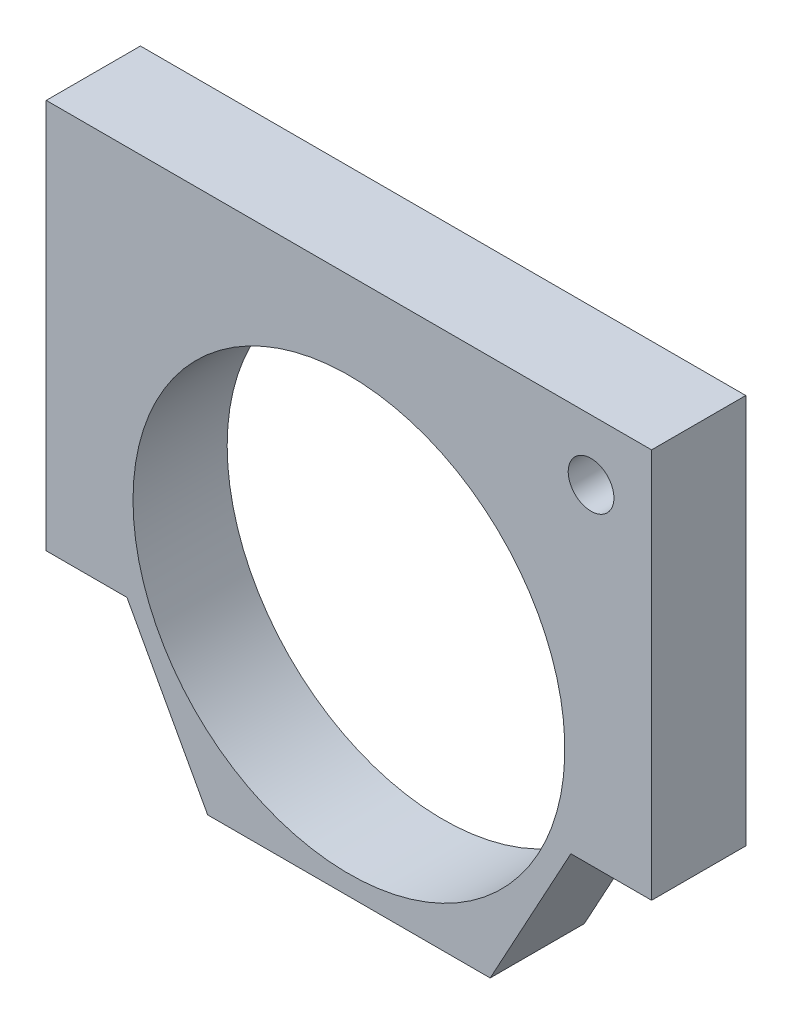
from build123d import *

# Parameters (mm, degrees)
SKETCH1_W                       = 45
SKETCH1_H                       = 40
SKETCH1_R                       = 16
BOSS_EXTRUDE1_DEPTH             = 3.5
M3X0_5_TAPPED_HOLE2_D           = 2.5
M3X0_5_TAPPED_HOLE2_DEPTH       = 25
M3X0_5_TAPPED_HOLE2_TIP         = 0.751075774
CUT_EXTRUDE1_DEPTH              = 5
CBORE_FOR_M3_SBHCS1_D           = 3.4
CBORE_FOR_M3_SBHCS1_DEPTH       = 7
CBORE_FOR_M3_SBHCS1_CBORE_D     = 6.7
CBORE_FOR_M3_SBHCS1_CBORE_DEPTH = 2.65
CBORE_FOR_M3_SBHCS1_TIP         = 1.021463052
F_3D_PRINTING_TOLERANCE_BY      = 0.05


with BuildPart() as part:
    # Sketch1 → Boss-Extrude1 (new, symmetric)
    with BuildSketch(Plane.XY):
        Rectangle(SKETCH1_W, SKETCH1_H)
        with Locations((0, -2.5)):
            Circle(SKETCH1_R, mode=Mode.SUBTRACT)
    extrude(amount=BOSS_EXTRUDE1_DEPTH, both=True)

    # M3x0.5 Tapped Hole2
    with Locations(Plane(origin=(0, -25, 71.05), x_dir=(0, 0, 1), z_dir=(0, -1, 0))):
        with Locations((-41.05, -18.5), (-71.05, 18.5), (-71.05, -18.5), (-41.05, 18.5)):
            Hole(M3X0_5_TAPPED_HOLE2_D / 2, depth=M3X0_5_TAPPED_HOLE2_DEPTH)
            with Locations((0, 0, -(M3X0_5_TAPPED_HOLE2_DEPTH + M3X0_5_TAPPED_HOLE2_TIP / 2))):  # 118° drill point
                Cone(0, M3X0_5_TAPPED_HOLE2_D / 2, M3X0_5_TAPPED_HOLE2_TIP, mode=Mode.SUBTRACT)

    # Sketch7 → Cut-Extrude1 (cut, symmetric)
    with BuildSketch(Plane.XY):
        Polygon((10.5, -20), (16.5, -9), (22.5, -9), (22.5, -20), align=None)
        Polygon((-10.5, -20), (-16.5, -9), (-22.5, -9), (-22.5, -20), align=None)
    extrude(amount=CUT_EXTRUDE1_DEPTH, both=True, mode=Mode.SUBTRACT)

    # CBORE for M3 SBHCS1
    with Locations(Plane(origin=(0, -2.5, -3.5), x_dir=(-1, 0, 0), z_dir=(0, 0, -1))):
        with Locations((-18, 18)):
            CounterBoreHole(CBORE_FOR_M3_SBHCS1_D / 2, CBORE_FOR_M3_SBHCS1_CBORE_D / 2, CBORE_FOR_M3_SBHCS1_CBORE_DEPTH, depth=CBORE_FOR_M3_SBHCS1_DEPTH)
            with Locations((0, 0, -(CBORE_FOR_M3_SBHCS1_DEPTH + CBORE_FOR_M3_SBHCS1_TIP / 2))):  # 118° drill point
                Cone(0, CBORE_FOR_M3_SBHCS1_D / 2, CBORE_FOR_M3_SBHCS1_TIP, mode=Mode.SUBTRACT)

    # 3D printing tolerance: a curved face moved inward by 0.05
    add(Solid.thicken(part.faces().sort_by_distance((-16, -2.5, 0))[0], -F_3D_PRINTING_TOLERANCE_BY), mode=Mode.SUBTRACT)


solid = part.part
